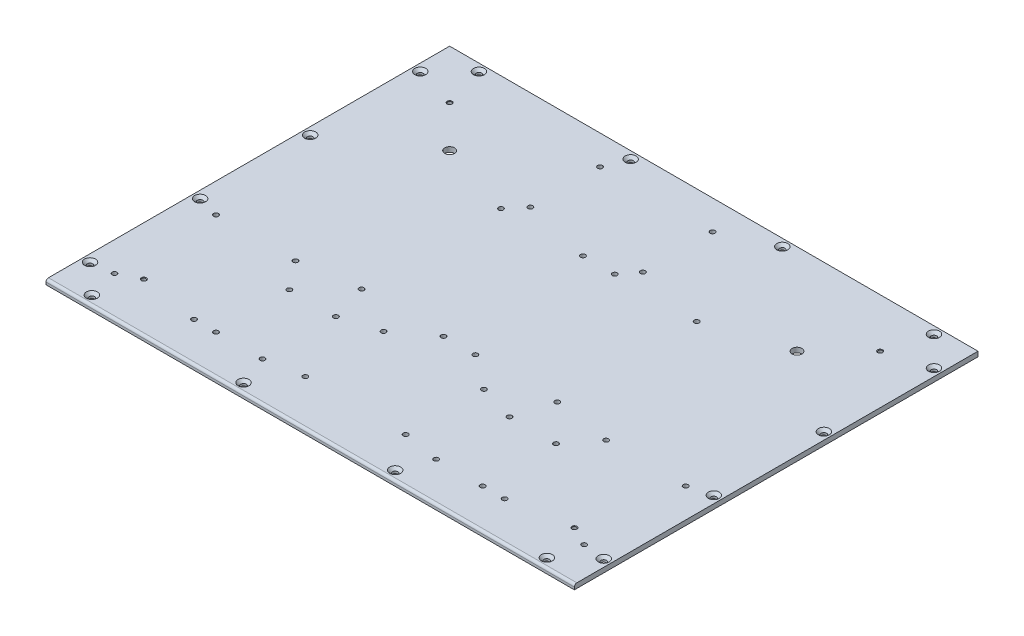
from build123d import *

# Parameters (mm, degrees)
SKETCH_1_W                     = 432
SKETCH_1_H                     = 330
EXTRUDE_1_DEPTH                = 4
HOLE_WIZARD_M4_1_AT_2_COUNT    = 2
HOLE_WIZARD_M4_1_AT_2_PITCH    = 90
HOLE_WIZARD_M4_1_AT_3_COUNT    = 2
HOLE_WIZARD_M4_1_AT_3_PITCH    = 180
HOLE_WIZARD_M4_1_AT_4_COUNT    = 2
HOLE_WIZARD_M4_1_AT_4_PITCH    = 270
HOLE_WIZARD_M4_1_AT_5_COUNT    = 2
HOLE_WIZARD_M4_1_AT_5_PITCH    = 293.48296373
HOLE_WIZARD_M4_1_AT_6_COUNT    = 2
HOLE_WIZARD_M4_1_AT_6_PITCH    = 327.811302429
HOLE_WIZARD_M4_1_AT_7_COUNT    = 2
HOLE_WIZARD_M4_1_AT_7_PITCH    = 399.424899074
HOLE_WIZARD_M4_1_AT_8_COUNT    = 2
HOLE_WIZARD_M4_1_AT_8_PITCH    = 492.31316253
HOLE_WIZARD_M4_1_AT_9_COUNT    = 2
HOLE_WIZARD_M4_1_AT_9_PITCH    = 499.299509313
HOLE_WIZARD_M4_1_AT_10_COUNT   = 2
HOLE_WIZARD_M4_1_AT_10_PITCH   = 456.946386352
HOLE_WIZARD_M4_1_AT_11_COUNT   = 2
HOLE_WIZARD_M4_1_AT_11_PITCH   = 429.534631898
HOLE_WIZARD_M4_1_AT_12_COUNT   = 2
HOLE_WIZARD_M4_1_AT_12_PITCH   = 420
HOLE_WIZARD_M4_1_AT_13_COUNT   = 2
HOLE_WIZARD_M4_1_AT_13_PITCH   = 396.726606116
HOLE_WIZARD_M4_1_AT_14_COUNT   = 2
HOLE_WIZARD_M4_1_AT_14_PITCH   = 273.056770654
HOLE_WIZARD_M4_1_AT_15_COUNT   = 2
HOLE_WIZARD_M4_1_AT_15_PITCH   = 149.933318512
HOLE_WIZARD_M4_1_AT_16_COUNT   = 2
HOLE_WIZARD_M4_1_AT_16_PITCH   = 33.941125497
FILLET_1_R                     = 2
HOLE_WIZARD_8_0_8_2_D          = 8
HOLE_WIZARD_4_0_4_1_D          = 4
HOLE_WIZARD_4_0_4_1_DEPTH      = 5
HOLE_WIZARD_4_0_4_1_TIP        = 1.201721238
HOLE_WIZARD_M4_1_2_D           = 3.3
HOLE_WIZARD_M4_1_2_CSINK_D     = 4.05
HOLE_WIZARD_M4_1_2_CSINK_ANGLE = 90
HOLE_WIZARD_4_0_4_2_D          = 4
HOLE_WIZARD_4_0_4_3_D          = 4
HOLE_WIZARD_4_0_4_3_DEPTH      = 5
HOLE_WIZARD_4_0_4_3_TIP        = 1.201721238


with BuildPart() as part:
    # 草圖1 → 填料-伸長1 (new body)
    with BuildSketch(Plane(origin=(0, 0, 0), x_dir=(1, 0, 0), z_dir=(0, 1, 0))):
        with Locations((216, 165)):
            Rectangle(SKETCH_1_W, SKETCH_1_H)
    extrude(amount=EXTRUDE_1_DEPTH)

    # 草圖2 → Hole Wizard M4 _1 (revolve, cut)
    with BuildSketch(Plane(origin=(6, 4, -300), x_dir=(0, 0, 1), z_dir=(1, 0, 0))):
        Polygon((0, 0), (0, 4), (2.25, 4), (2.25, 2.23), (4.48, 0), align=None)
    hole_wizard_m4_1 = revolve(axis=Axis((6, 10.35, -300), (0, -1, 0)), mode=Mode.SUBTRACT)

    # Hole Wizard M4 _1 at 2: Hole Wizard M4 _1 ×2
    with Locations(*[(0, 0, i * HOLE_WIZARD_M4_1_AT_2_PITCH) for i in range(1, HOLE_WIZARD_M4_1_AT_2_COUNT)]):
        add(hole_wizard_m4_1, mode=Mode.SUBTRACT)

    # Hole Wizard M4 _1 at 3: Hole Wizard M4 _1 ×2
    with Locations(*[(0, 0, i * HOLE_WIZARD_M4_1_AT_3_PITCH) for i in range(1, HOLE_WIZARD_M4_1_AT_3_COUNT)]):
        add(hole_wizard_m4_1, mode=Mode.SUBTRACT)

    # Hole Wizard M4 _1 at 4: Hole Wizard M4 _1 ×2
    with Locations(*[(0, 0, i * HOLE_WIZARD_M4_1_AT_4_PITCH) for i in range(1, HOLE_WIZARD_M4_1_AT_4_COUNT)]):
        add(hole_wizard_m4_1, mode=Mode.SUBTRACT)

    # Hole Wizard M4 _1 at 5: Hole Wizard M4 _1 ×2
    with Locations(*[Vector(0.081776467, 0, 0.996650696) * (i * HOLE_WIZARD_M4_1_AT_5_PITCH) for i in range(1, HOLE_WIZARD_M4_1_AT_5_COUNT)]):
        add(hole_wizard_m4_1, mode=Mode.SUBTRACT)

    # Hole Wizard M4 _1 at 6: Hole Wizard M4 _1 ×2
    with Locations(*[Vector(0.451479247, 0, 0.89228162) * (i * HOLE_WIZARD_M4_1_AT_6_PITCH) for i in range(1, HOLE_WIZARD_M4_1_AT_6_COUNT)]):
        add(hole_wizard_m4_1, mode=Mode.SUBTRACT)

    # Hole Wizard M4 _1 at 7: Hole Wizard M4 _1 ×2
    with Locations(*[Vector(0.680979079, 0, 0.73230287) * (i * HOLE_WIZARD_M4_1_AT_7_PITCH) for i in range(1, HOLE_WIZARD_M4_1_AT_7_COUNT)]):
        add(hole_wizard_m4_1, mode=Mode.SUBTRACT)

    # Hole Wizard M4 _1 at 8: Hole Wizard M4 _1 ×2
    with Locations(*[Vector(0.804366062, 0, 0.594134023) * (i * HOLE_WIZARD_M4_1_AT_8_PITCH) for i in range(1, HOLE_WIZARD_M4_1_AT_8_COUNT)]):
        add(hole_wizard_m4_1, mode=Mode.SUBTRACT)

    # Hole Wizard M4 _1 at 9: Hole Wizard M4 _1 ×2
    with Locations(*[Vector(0.841178475, 0, 0.540757591) * (i * HOLE_WIZARD_M4_1_AT_9_PITCH) for i in range(1, HOLE_WIZARD_M4_1_AT_9_COUNT)]):
        add(hole_wizard_m4_1, mode=Mode.SUBTRACT)

    # Hole Wizard M4 _1 at 10: Hole Wizard M4 _1 ×2
    with Locations(*[Vector(0.91914503, 0, 0.393919299) * (i * HOLE_WIZARD_M4_1_AT_10_PITCH) for i in range(1, HOLE_WIZARD_M4_1_AT_10_COUNT)]):
        add(hole_wizard_m4_1, mode=Mode.SUBTRACT)

    # Hole Wizard M4 _1 at 11: Hole Wizard M4 _1 ×2
    with Locations(*[Vector(0.977802414, 0, 0.209529089) * (i * HOLE_WIZARD_M4_1_AT_11_PITCH) for i in range(1, HOLE_WIZARD_M4_1_AT_11_COUNT)]):
        add(hole_wizard_m4_1, mode=Mode.SUBTRACT)

    # Hole Wizard M4 _1 at 12: Hole Wizard M4 _1 ×2
    with Locations(*[(i * HOLE_WIZARD_M4_1_AT_12_PITCH, 0, 0) for i in range(1, HOLE_WIZARD_M4_1_AT_12_COUNT)]):
        add(hole_wizard_m4_1, mode=Mode.SUBTRACT)

    # Hole Wizard M4 _1 at 13: Hole Wizard M4 _1 ×2
    with Locations(*[Vector(0.998168497, 0, -0.06049506) * (i * HOLE_WIZARD_M4_1_AT_13_PITCH) for i in range(1, HOLE_WIZARD_M4_1_AT_13_COUNT)]):
        add(hole_wizard_m4_1, mode=Mode.SUBTRACT)

    # Hole Wizard M4 _1 at 14: Hole Wizard M4 _1 ×2
    with Locations(*[Vector(0.99612985, 0, -0.08789381) * (i * HOLE_WIZARD_M4_1_AT_14_PITCH) for i in range(1, HOLE_WIZARD_M4_1_AT_14_COUNT)]):
        add(hole_wizard_m4_1, mode=Mode.SUBTRACT)

    # Hole Wizard M4 _1 at 15: Hole Wizard M4 _1 ×2
    with Locations(*[Vector(0.987105478, 0, -0.160071159) * (i * HOLE_WIZARD_M4_1_AT_15_PITCH) for i in range(1, HOLE_WIZARD_M4_1_AT_15_COUNT)]):
        add(hole_wizard_m4_1, mode=Mode.SUBTRACT)

    # Hole Wizard M4 _1 at 16: Hole Wizard M4 _1 ×2
    with Locations(*[Vector(0.707106781, 0, -0.707106781) * (i * HOLE_WIZARD_M4_1_AT_16_PITCH) for i in range(1, HOLE_WIZARD_M4_1_AT_16_COUNT)]):
        add(hole_wizard_m4_1, mode=Mode.SUBTRACT)

    # 圓角1
    fillet_1_edges = [part.edges().sort_by_distance(p)[0] for p in [
        (216, 4, 0),
    ]]
    fillet(fillet_1_edges, radius=FILLET_1_R)

    # Ø8.0 (8) 直徑孔2 (through all)
    with Locations(Plane(origin=(0, 0, 0), x_dir=(-1, 0, 0), z_dir=(0, -1, 0))):
        with Locations((-74, 256), (-358, 256)):
            Hole(HOLE_WIZARD_8_0_8_2_D / 2)

    # Ø4.0 (4) 直徑孔1
    with Locations(Plane(origin=(0, 0, 0), x_dir=(-1, 0, 0), z_dir=(0, -1, 0))):
        with Locations((-107, 32), (-145, 32), (-107, 92), (-145, 92), (-147, 249), (-239, 249), (-239, 306), (-147, 306), (-287, 92), (-325, 92), (-287, 32), (-325, 32)):
            Hole(HOLE_WIZARD_4_0_4_1_D / 2, depth=HOLE_WIZARD_4_0_4_1_DEPTH)
            with Locations((0, 0, -(HOLE_WIZARD_4_0_4_1_DEPTH + HOLE_WIZARD_4_0_4_1_TIP / 2))):  # 118° drill point
                Cone(0, HOLE_WIZARD_4_0_4_1_D / 2, HOLE_WIZARD_4_0_4_1_TIP, mode=Mode.SUBTRACT)

    # Hole Wizard M4 _1 2 (through all)
    with Locations(Plane(origin=(0, 4, 0), x_dir=(1, 0, 0), z_dir=(0, 1, 0))):
        with Locations((40, 290), (40, 40), (392, 40), (392, 290)):
            CounterSinkHole(HOLE_WIZARD_M4_1_2_D / 2, HOLE_WIZARD_M4_1_2_CSINK_D / 2, counter_sink_angle=HOLE_WIZARD_M4_1_2_CSINK_ANGLE)

    # Ø4.0 (4) 直徑孔2 (through all)
    with Locations(Plane(origin=(0, 0, 0), x_dir=(-1, 0, 0), z_dir=(0, -1, 0))):
        with Locations((-24, 32), (-89, 32), (-24, 115), (-89, 115), (-203, 122), (-203, 236), (-136, 236), (-136, 122), (-229, 122), (-296, 236), (-296, 122), (-408, 32), (-408, 115), (-343, 115), (-343, 32), (-229, 236)):
            Hole(HOLE_WIZARD_4_0_4_2_D / 2)

    # Ø4.0 (4) 直徑孔3
    with Locations(Plane(origin=(0, 0, 0), x_dir=(-1, 0, 0), z_dir=(0, -1, 0))):
        with Locations((-175, 37), (-257, 37), (-175, 101), (-257, 101)):
            Hole(HOLE_WIZARD_4_0_4_3_D / 2, depth=HOLE_WIZARD_4_0_4_3_DEPTH)
            with Locations((0, 0, -(HOLE_WIZARD_4_0_4_3_DEPTH + HOLE_WIZARD_4_0_4_3_TIP / 2))):  # 118° drill point
                Cone(0, HOLE_WIZARD_4_0_4_3_D / 2, HOLE_WIZARD_4_0_4_3_TIP, mode=Mode.SUBTRACT)


solid = part.part
